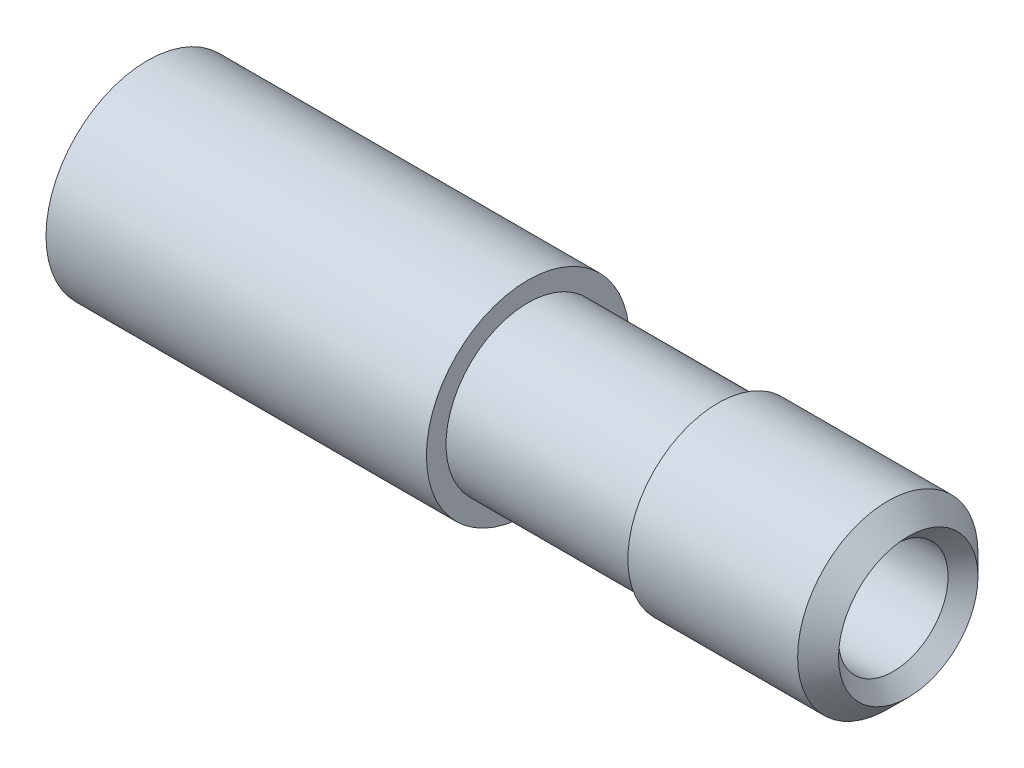
from build123d import *

# Parameters (mm, degrees)
SKETCH1_R           = 4
BOSS_EXTRUDE2_DEPTH = 30
SKETCH3_R           = 2.5
CUT_EXTRUDE1_DEPTH  = 12
SKETCH4_R           = 2.16
CUT_EXTRUDE2_DEPTH  = 31
SKETCH10_OUTSIDE_W  = 16.412
SKETCH10_OUTSIDE_H  = 16.412
SKETCH10_OUTSIDE_R  = 3.556
CUT_EXTRUDE3_DEPTH  = 15
SKETCH18_OUTSIDE_W  = 16.412
SKETCH18_OUTSIDE_H  = 16.412
SKETCH18_OUTSIDE_R  = 3.225571995
CUT_EXTRUDE4_DEPTH  = 7.5


with BuildPart() as part:
    # Sketch1 → Boss-Extrude2 (new body)
    with BuildSketch(Plane(origin=(0, 0, 0), x_dir=(0, 0, -1), z_dir=(1, 0, 0))):
        Circle(SKETCH1_R)
    extrude(amount=BOSS_EXTRUDE2_DEPTH)

    # Sketch3 → Cut-Extrude1 (cut)
    with BuildSketch(Plane.ZY):
        Circle(SKETCH3_R)
    extrude(amount=-CUT_EXTRUDE1_DEPTH, mode=Mode.SUBTRACT)

    # Sketch4 → Cut-Extrude2 (cut, through all)
    with BuildSketch(Plane(origin=(30, 0, 0), x_dir=(0, 0, -1), z_dir=(1, 0, 0))):
        Circle(SKETCH4_R)
    extrude(amount=-CUT_EXTRUDE2_DEPTH, mode=Mode.SUBTRACT)

    # Sketch10 outside → Cut-Extrude3 (cut)
    with BuildSketch(Plane(origin=(30, 0, 0), x_dir=(0, 0, -1), z_dir=(1, 0, 0))):
        Rectangle(SKETCH10_OUTSIDE_W, SKETCH10_OUTSIDE_H)
        Circle(SKETCH10_OUTSIDE_R, mode=Mode.SUBTRACT)
    extrude(amount=-CUT_EXTRUDE3_DEPTH, mode=Mode.SUBTRACT)

    # Sketch18 outside → Cut-Extrude4 (cut)
    with BuildSketch(Plane(origin=(15, 0, 0), x_dir=(0, 0, -1), z_dir=(1, 0, 0))):
        Rectangle(SKETCH18_OUTSIDE_W, SKETCH18_OUTSIDE_H)
        Circle(SKETCH18_OUTSIDE_R, mode=Mode.SUBTRACT)
    extrude(amount=CUT_EXTRUDE4_DEPTH, mode=Mode.SUBTRACT)

    # Sketch17 → Cut-Revolve1 (revolve, cut)
    with BuildSketch(Plane.XY):
        Polygon((28.84073404, 3.90926596), (30, 2.75), (28.84073404, 1.59073404), (31.351449917, 1.59073404), (31.351449917, 3.90926596), align=None)
    revolve(axis=Axis((12, 0, 0), (1, 0, 0)), mode=Mode.SUBTRACT)


solid = part.part
